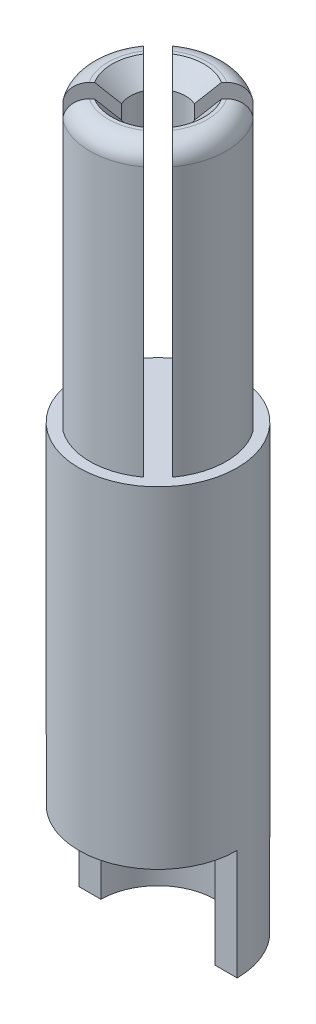
from build123d import *

# Parameters (mm, degrees)
CORTE_EXTRUS_O3_START = -7.8
ESBO_O2_R             = 2.15
CORTE_EXTRUS_O3_DEPTH = 7.8
ESBO_O3_W             = 4.788650246
ESBO_O3_H             = 2.452019704
CORTE_EXTRUS_O4_DEPTH = 3
CHANFRO1_SIZE         = 0.5
FILETE1_R             = 0.5


with BuildPart() as part:
    # Esboço1 → Revolução1 (revolve)
    with BuildSketch(Plane.XY):
        Polygon((0, 10), (0, 19.8), (2.15, 19.8), (2.15, 0), (1.55, 0), (1.55, 7.5), align=None)
    revolve(axis=Axis((0, 10, 0), (0, 1, 0)))

    # Esboço2 → Corte-extrusão3 (cut)
    with BuildSketch(Plane(origin=(0, 19.8, 0), x_dir=(1, 0, 0), z_dir=(0, 1, 0)).offset(CORTE_EXTRUS_O3_START)):
        Circle(ESBO_O2_R)
        with BuildLine():
            Line((-1.099159758, 1.488068488), (-0.298939494, 0.687848224))
            ThreePointArc((-0.298939494, 0.687848224), (0, 0.75), (0.298939494, 0.687848224))
            Line((0.298939494, 0.687848224), (1.099159758, 1.488068488))
            ThreePointArc((1.099159758, 1.488068488), (0, 1.85), (-1.099159758, 1.488068488))
        make_face(mode=Mode.SUBTRACT)
        with BuildLine():
            Line((-1.488068488, 1.099159758), (-0.687848224, 0.298939494))
            ThreePointArc((-0.687848224, 0.298939494), (-0.75, 0), (-0.687848224, -0.298939494))
            Line((-0.687848224, -0.298939494), (-1.488068488, -1.099159758))
            ThreePointArc((-1.488068488, -1.099159758), (-1.85, 0), (-1.488068488, 1.099159758))
        make_face(mode=Mode.SUBTRACT)
        with BuildLine():
            Line((1.099159758, -1.488068488), (0.298939494, -0.687848224))
            ThreePointArc((0.298939494, -0.687848224), (0, -0.75), (-0.298939494, -0.687848224))
            Line((-0.298939494, -0.687848224), (-1.099159758, -1.488068488))
            ThreePointArc((-1.099159758, -1.488068488), (0, -1.85), (1.099159758, -1.488068488))
        make_face(mode=Mode.SUBTRACT)
        with BuildLine():
            Line((1.488068488, 1.099159758), (0.687848224, 0.298939494))
            ThreePointArc((0.687848224, 0.298939494), (0.75, 0), (0.687848224, -0.298939494))
            Line((0.687848224, -0.298939494), (1.488068488, -1.099159758))
            ThreePointArc((1.488068488, -1.099159758), (1.85, 0), (1.488068488, 1.099159758))
        make_face(mode=Mode.SUBTRACT)
    extrude(amount=CORTE_EXTRUS_O3_DEPTH, mode=Mode.SUBTRACT)

    # Esboço3 → Corte-extrusão4 (cut)
    with BuildSketch(Plane.XZ):
        with Locations((0, 1.226009852)):
            Rectangle(ESBO_O3_W, ESBO_O3_H)
    extrude(amount=-CORTE_EXTRUS_O4_DEPTH, mode=Mode.SUBTRACT)

    # Chanfro1
    chanfro1_edges = [part.edges().sort_by_distance(p)[0] for p in [
        (0, 19.8, 0.75),
        (0.75, 19.8, 0),
        (0, 19.8, -0.75),
        (-0.75, 19.8, 0),
    ]]
    chamfer(chanfro1_edges, length=CHANFRO1_SIZE)

    # Filete1
    filete1_edges = [part.edges().sort_by_distance(p)[0] for p in [
        (1.85, 19.8, 0),
        (0, 19.8, -1.85),
        (0, 19.8, 1.85),
        (-1.85, 19.8, 0),
    ]]
    fillet(filete1_edges, radius=FILETE1_R)


solid = part.part
